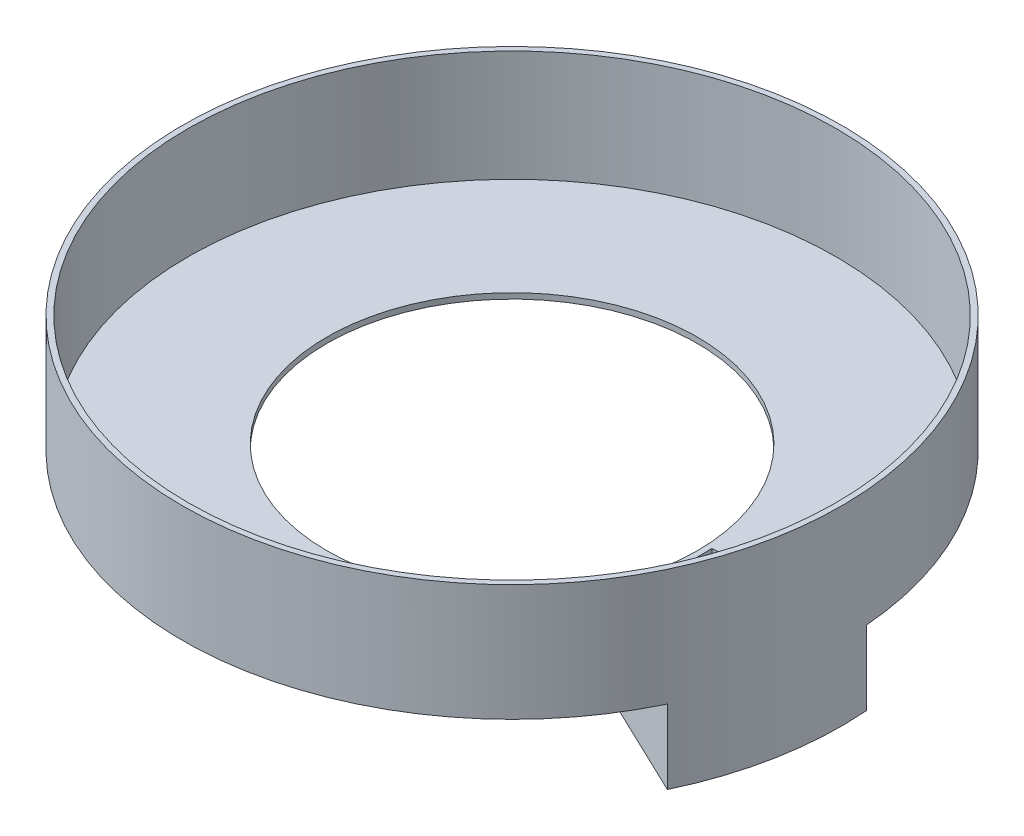
from build123d import *
from build123d.topology import SkipClean

# Parameters (mm, degrees)
SKETCH2_R                 = 178
SKETCH2_R_2               = 100
BOSS_EXTRUDE1_DEPTH       = 3
SKETCH3_R                 = 178
SKETCH3_R_2               = 175
BOSS_EXTRUDE2_DEPTH       = 60
CUT_EXTRUDE2_START        = -25
CUT_EXTRUDE2_DEPTH        = 25
BOSS_EXTRUDE17_DEPTH      = 40
BOSS_EXTRUDE17_DEPTH_BACK = 3


with BuildPart() as part:
    # Sketch2 → Boss-Extrude1 (new body)
    with BuildSketch(Plane(origin=(0, 0, 0), x_dir=(1, 0, 0), z_dir=(0, 1, 0))):
        Circle(SKETCH2_R)
        Circle(SKETCH2_R_2, mode=Mode.SUBTRACT)
    extrude(amount=BOSS_EXTRUDE1_DEPTH)

    # Sketch3 → Boss-Extrude2 (add)
    with BuildSketch(Plane(origin=(0, 3, 0), x_dir=(1, 0, 0), z_dir=(0, 1, 0))):
        Circle(SKETCH3_R)
        Circle(SKETCH3_R_2, mode=Mode.SUBTRACT)
    extrude(amount=BOSS_EXTRUDE2_DEPTH)

    # Sketch5 → Cut-Extrude2 (cut)
    with BuildSketch(Plane(origin=(0, 3, 0), x_dir=(1, 0, 0), z_dir=(0, 1, 0)).offset(CUT_EXTRUDE2_START)):
        with BuildLine():
            Line((174.470835958, 13.59880142), (99.697620548, 7.770743669))
            ThreePointArc((99.697620548, 7.770743669), (99.924376542, 3.888312311), (100, 0))
            ThreePointArc((100, 0), (97.525905257, -22.106510438), (90.226043925, -43.11914885))
            Line((90.226043925, -43.11914885), (157.895576869, -75.458510488))
            ThreePointArc((157.895576869, -75.458510488), (170.6703342, -38.686393266), (175, 0))
            ThreePointArc((175, 0), (174.867658949, 6.804546543), (174.470835958, 13.59880142))
        make_face()
    extrude(amount=CUT_EXTRUDE2_DEPTH, mode=Mode.SUBTRACT)

    # Sketch16 → Boss-Extrude17 (add, two sides: drawn at the far end of the back side and taken through both)
    with SkipClean():  # the faces are left unmerged after this step: merging them gives an invalid solid
        with BuildSketch(Plane.XZ.offset(-BOSS_EXTRUDE17_DEPTH_BACK)):
            with BuildLine():
                Line((160.602358187, 76.752084954), (90.226043925, 43.11914885))
                ThreePointArc((90.226043925, 43.11914885), (98.311722962, 18.29768095), (99.697620548, -7.770743669))
                Line((99.697620548, -7.770743669), (177.461764575, -13.83192373))
                ThreePointArc((177.461764575, -13.83192373), (174.994866873, 32.569872091), (160.602358187, 76.752084954))
            make_face()
            with BuildLine():
                Line((159.165948647, 72.740640575), (94.186972199, 41.687099538))
                ThreePointArc((94.186972199, 41.687099538), (101.261074651, 18.846611379), (102.878105019, -5.009541657))
                Line((102.878105019, -5.009541657), (174.678319853, -10.605874466))
                ThreePointArc((174.678319853, -10.605874466), (172.045515184, 32.020941663), (159.165948647, 72.740640575))
            make_face(mode=Mode.SUBTRACT)
        extrude(amount=BOSS_EXTRUDE17_DEPTH + BOSS_EXTRUDE17_DEPTH_BACK)


solid = part.part
